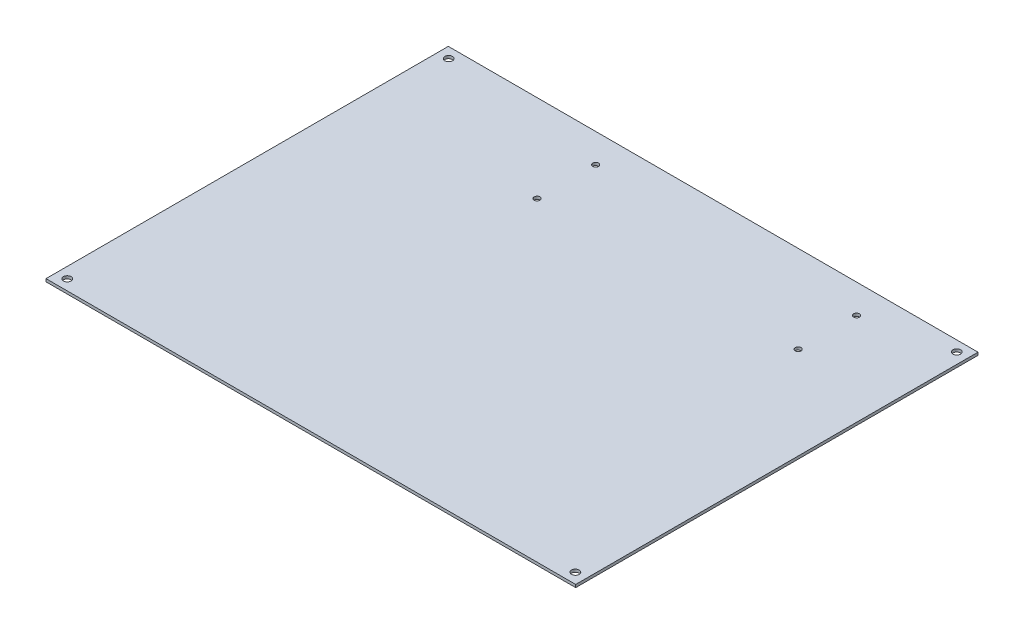
from build123d import *

# Parameters (mm, degrees)
SKETCH9_W                  = 380.5
SKETCH9_H                  = 289
BOSS_EXTRUDE2_DEPTH        = 2
M5_CLEARANCE_HOLE1_D       = 5.5
MIRROR2_COPY_1_D           = 5.5
F_4_2_4_2_DIAMETER_HOLE1_D = 4.2


with BuildPart() as part:
    # Sketch9 → Boss-Extrude2 (new body)
    with BuildSketch(Plane(origin=(0, 0, 0), x_dir=(1, 0, 0), z_dir=(0, 1, 0))):
        Rectangle(SKETCH9_W, SKETCH9_H)
    extrude(amount=BOSS_EXTRUDE2_DEPTH)

    # M5 Clearance Hole1 (through all)
    with Locations(Plane(origin=(0, 2, 0), x_dir=(1, 0, 0), z_dir=(0, 1, 0))):
        with Locations((182.5, 137)):
            m5_clearance_hole1 = Hole(M5_CLEARANCE_HOLE1_D / 2)

    # Mirror1: M5 Clearance Hole1 across plane
    add(m5_clearance_hole1.mirror(Plane.XY), mode=Mode.SUBTRACT)

    # Mirror2: M5 Clearance Hole1 across plane
    add(m5_clearance_hole1.mirror(Plane(origin=(0, 0, 0), x_dir=(0, 0, 1), z_dir=(1, 0, 0))), mode=Mode.SUBTRACT)

    # Mirror2 copy 1 (through all)
    with Locations(Plane(origin=(0, 2, 0), x_dir=(-1, 0, 0), z_dir=(0, 1, 0))):
        with Locations((182.5, 137)):
            Hole(MIRROR2_COPY_1_D / 2)

    # Ø4.2 (4.2) Diameter Hole1 (through all)
    with Locations(Plane(origin=(0, 2, 0), x_dir=(1, 0, 0), z_dir=(0, 1, 0))):
        with Locations((-63.670911712, 123.724418587), (-63.670911465, 81.719974794), (123.822278547, 81.708178414), (123.8222783, 123.712622207)):
            Hole(F_4_2_4_2_DIAMETER_HOLE1_D / 2)


solid = part.part
